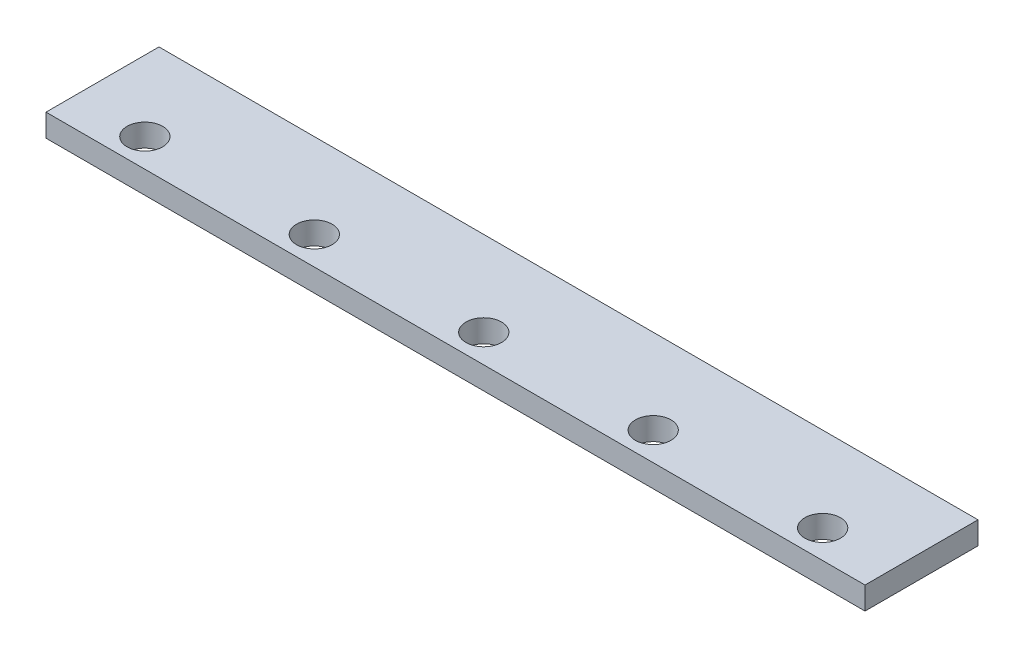
from build123d import *

# Parameters (mm, degrees)
SKETCH8_W           = 580
SKETCH8_H           = 80
SKETCH8_R           = 12.6
BOSS_EXTRUDE9_DEPTH = 16


with BuildPart() as part:
    # Sketch8 → Boss-Extrude9 (new body)
    with BuildSketch(Plane(origin=(0, 0, 0), x_dir=(1, 0, 0), z_dir=(0, 1, 0))):
        with Locations((290, 40)):
            Rectangle(SKETCH8_W, SKETCH8_H)
        with Locations(Location((530, 20, 0), (0, 0, 270))):  # turned: the seam where the file's is
            Circle(SKETCH8_R, mode=Mode.SUBTRACT)
        with Locations(Location((410, 20, 0), (0, 0, 270))):  # turned: the seam where the file's is
            Circle(SKETCH8_R, mode=Mode.SUBTRACT)
        with Locations(Location((290, 20, 0), (0, 0, 270))):  # turned: the seam where the file's is
            Circle(SKETCH8_R, mode=Mode.SUBTRACT)
        with Locations(Location((50, 20, 0), (0, 0, 90))):  # turned: the seam where the file's is
            Circle(SKETCH8_R, mode=Mode.SUBTRACT)
        with Locations(Location((170, 20, 0), (0, 0, 90))):  # turned: the seam where the file's is
            Circle(SKETCH8_R, mode=Mode.SUBTRACT)
    extrude(amount=BOSS_EXTRUDE9_DEPTH)


solid = part.part
